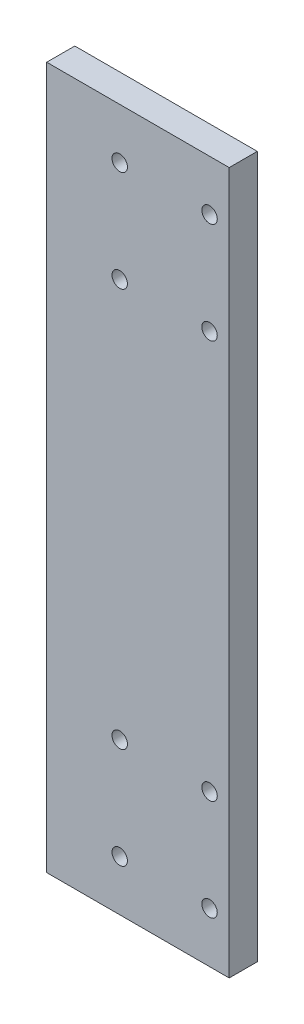
from build123d import *

# Parameters (mm, degrees)
SKETCH_1_W                = 65
SKETCH_1_H                = 250
EXTRUDE_1_DEPTH           = 10
HOLE_WIZARD_1_D           = 5.5
HOLE_WIZARD_1_DEPTH       = 18
HOLE_WIZARD_1_CBORE_D     = 10
HOLE_WIZARD_1_CBORE_DEPTH = 5.7
HOLE_WIZARD_1_TIP         = 1.652366702
HOLE_WIZARD_M6_1_D        = 5
HOLE_WIZARD_M6_1_DEPTH    = 17
HOLE_WIZARD_M6_1_TIP      = 1.502151548


with BuildPart() as part:
    # 草图1 → 凸台-拉伸1 (new body)
    with BuildSketch(Plane.XY):
        Rectangle(SKETCH_1_W, SKETCH_1_H)
    extrude(amount=EXTRUDE_1_DEPTH)

    # 打孔尺寸(%根据)内六角圆柱头螺钉的类型1
    with Locations(Plane(origin=(-6.5, 107, 0), x_dir=(-1, 0, 0), z_dir=(0, 0, -1))):
        with Locations((0, 0), (-32, 0), (0, -36), (-32, -36), (-32, -178), (0, -178), (0, -214), (-32, -214)):
            CounterBoreHole(HOLE_WIZARD_1_D / 2, HOLE_WIZARD_1_CBORE_D / 2, HOLE_WIZARD_1_CBORE_DEPTH, depth=HOLE_WIZARD_1_DEPTH)
            with Locations((0, 0, -(HOLE_WIZARD_1_DEPTH + HOLE_WIZARD_1_TIP / 2))):  # 118° drill point
                Cone(0, HOLE_WIZARD_1_D / 2, HOLE_WIZARD_1_TIP, mode=Mode.SUBTRACT)

    # M6 螺纹孔1
    with Locations(Plane(origin=(-32.5, -70, 5), x_dir=(0, -1, 0), z_dir=(-1, 0, 0))):
        with Locations((0, 0), (-35, 0), (-70, 0), (-105, 0), (-140, 0), (35, 0), (-175, 0)):
            Hole(HOLE_WIZARD_M6_1_D / 2, depth=HOLE_WIZARD_M6_1_DEPTH)
            with Locations((0, 0, -(HOLE_WIZARD_M6_1_DEPTH + HOLE_WIZARD_M6_1_TIP / 2))):  # 118° drill point
                Cone(0, HOLE_WIZARD_M6_1_D / 2, HOLE_WIZARD_M6_1_TIP, mode=Mode.SUBTRACT)


solid = part.part
